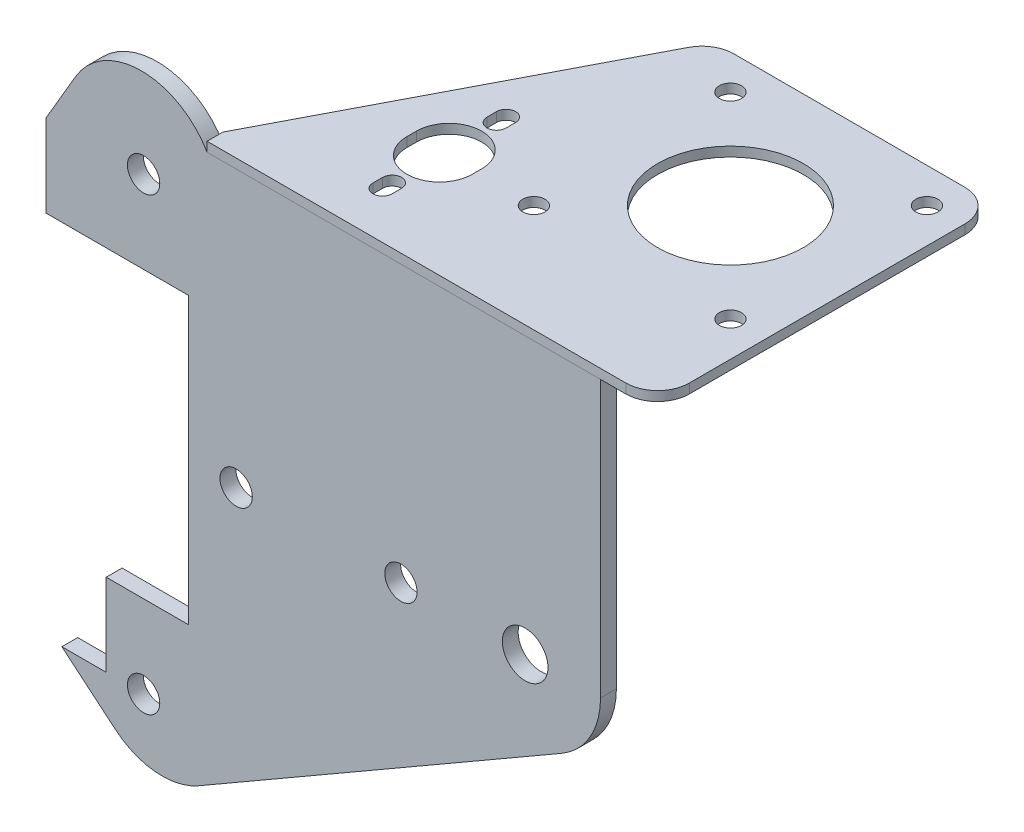
from build123d import *

# Parameters (mm, degrees)
SKETCH1_R           = 2.55
SKETCH1_R_2         = 3.6
BOSS_EXTRUDE1_DEPTH = 2.5
SKETCH3_R           = 11.5
BOSS_EXTRUDE2_DEPTH = 1.5
SKETCH5_R           = 1.75
CUT_EXTRUDE1_DEPTH  = 91.291152611
FILLET1_R           = 5


with BuildPart() as part:
    # Sketch1 → Boss-Extrude1 (new body)
    with BuildSketch(Plane.XY):
        with BuildLine():
            Line((-75.205421971, 35.5), (-70.514036248, 43.53))
            ThreePointArc((-70.514036248, 43.53), (-60.152745925, 49.476599067), (-49.791455603, 43.53))
            Line((-49.791455603, 43.53), (12.294578029, 43.53))
            Line((12.294578029, 43.53), (12.294578029, 0))
            ThreePointArc((12.294578029, 0), (10.647416902, -6.147289015), (6.147289015, -10.647416902))
            Line((6.147289015, -10.647416902), (-51.136875585, -43.720444754))
            ThreePointArc((-51.136875585, -43.720444754), (-57.889166626, -45.217391639), (-64.278933096, -42.570663707))
            Line((-64.278933096, -42.570663707), (-72.705421971, -35.5))
            Line((-72.705421971, -35.5), (-65.705421971, -35.5))
            Line((-65.705421971, -35.5), (-65.705421971, -22.5))
            Line((-65.705421971, -22.5), (-52.705421971, -22.5))
            Line((-52.705421971, -22.5), (-52.705421971, 22.5))
            Line((-52.705421971, 22.5), (-75.205421971, 22.5))
            Line((-75.205421971, 22.5), (-75.205421971, 35.5))
        make_face()
        with Locations((-59.805421971, 35.5)):
            Circle(SKETCH1_R, mode=Mode.SUBTRACT)
        with Locations((-59.805421971, -35.52)):
            Circle(SKETCH1_R, mode=Mode.SUBTRACT)
        with Locations((-45.205421971, 0)):
            Circle(SKETCH1_R, mode=Mode.SUBTRACT)
        with Locations((-19.205421971, 0)):
            Circle(SKETCH1_R, mode=Mode.SUBTRACT)
        with Locations((0.394578029, 0)):
            Circle(SKETCH1_R_2, mode=Mode.SUBTRACT)
    extrude(amount=BOSS_EXTRUDE1_DEPTH)


with BuildPart() as body_2:
    # Sketch3 → Boss-Extrude2 (new body)
    with BuildSketch(Plane(origin=(0, 43.53, 0), x_dir=(1, 0, 0), z_dir=(0, 1, 0))):
        Polygon((-49.791455603, -2.5), (21.294578029, -2.5), (21.294578029, 51), (-23.231221686, 51), (-49.791455603, 0), align=None)
        with Locations((0.294578029, 30)):
            Circle(SKETCH3_R, mode=Mode.SUBTRACT)
        with BuildLine():
            Line((-24.355421971, 15.4), (-24.355421971, 13.9))
            ThreePointArc((-24.355421971, 13.9), (-29.505421971, 8.75), (-34.655421971, 13.9))
            Line((-34.655421971, 13.9), (-34.655421971, 15.4))
            ThreePointArc((-34.655421971, 15.4), (-29.505421971, 20.55), (-24.355421971, 15.4))
        make_face(mode=Mode.SUBTRACT)
        with BuildLine():
            Line((-28.005421971, 24.4), (-28.005421971, 22.9))
            ThreePointArc((-28.005421971, 22.9), (-29.505421971, 21.4), (-31.005421971, 22.9))
            Line((-31.005421971, 22.9), (-31.005421971, 24.4))
            ThreePointArc((-31.005421971, 24.4), (-29.505421971, 25.9), (-28.005421971, 24.4))
        make_face(mode=Mode.SUBTRACT)
        with BuildLine():
            Line((-28.005421971, 6.4), (-28.005421971, 4.9))
            ThreePointArc((-28.005421971, 4.9), (-29.505421971, 3.4), (-31.005421971, 4.9))
            Line((-31.005421971, 4.9), (-31.005421971, 6.4))
            ThreePointArc((-31.005421971, 6.4), (-29.505421971, 7.9), (-28.005421971, 6.4))
        make_face(mode=Mode.SUBTRACT)
    extrude(amount=BOSS_EXTRUDE2_DEPTH)

    # Sketch5 → Cut-Extrude1 (cut, through all)
    with BuildSketch(Plane(origin=(0, 45.03, 0), x_dir=(1, 0, 0), z_dir=(0, 1, 0))):
        with Locations((-15.215421971, 45.5)):
            Circle(SKETCH5_R)
        with Locations((-15.215421971, 14.49409974)):
            Circle(SKETCH5_R)
        with Locations((15.794578029, 45.5)):
            Circle(SKETCH5_R)
        with Locations((15.794578029, 14.49409974)):
            Circle(SKETCH5_R)
    extrude(amount=-CUT_EXTRUDE1_DEPTH, mode=Mode.SUBTRACT)

    # Fillet1
    fillet1_edges = [body_2.edges().sort_by_distance(p)[0] for p in [
        (-23.231221686, 44.28, -51),
        (21.294578029, 44.28, -51),
        (21.294578029, 44.28, 2.5),
    ]]
    fillet(fillet1_edges, radius=FILLET1_R)


solid = Compound([part.part, body_2.part])
